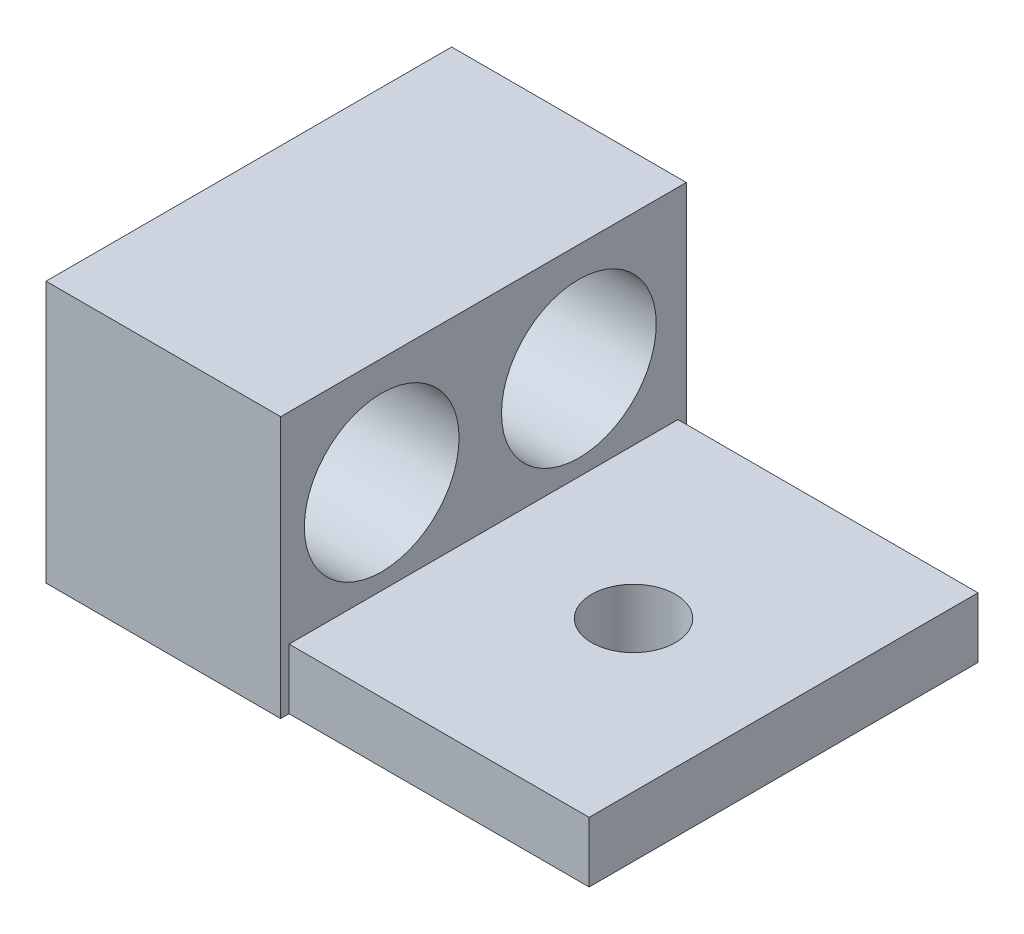
from build123d import *

# Parameters (mm, degrees)
SKETCH1_W           = 81.026
SKETCH1_H           = 39.624
BOSS_EXTRUDE1_DEPTH = 61.468
SKETCH5_W           = 45.466
SKETCH5_H           = 30.48
CUT_EXTRUDE1_DEPTH  = 62.468
SKETCH6_W           = 45.466
SKETCH6_H           = 1.27
CUT_EXTRUDE2_DEPTH  = 10.144
SKETCH7_R           = 6.35
CUT_EXTRUDE3_DEPTH  = 10.144
SKETCH8_R           = 11.7221
CUT_EXTRUDE4_DEPTH  = 36.56


with BuildPart() as part:
    # Sketch1 → Boss-Extrude1 (new body)
    with BuildSketch(Plane.XY):
        with Locations((40.513, 19.812)):
            Rectangle(SKETCH1_W, SKETCH1_H)
    extrude(amount=-BOSS_EXTRUDE1_DEPTH)

    # Sketch5 → Cut-Extrude1 (cut, through all)
    with BuildSketch(Plane.XY):
        with Locations((58.293, 24.384)):
            Rectangle(SKETCH5_W, SKETCH5_H)
    extrude(amount=-CUT_EXTRUDE1_DEPTH, mode=Mode.SUBTRACT)

    # Sketch6 → Cut-Extrude2 (cut, through all)
    with BuildSketch(Plane(origin=(0, 9.144, 0), x_dir=(1, 0, 0), z_dir=(0, 1, 0))):
        with Locations((58.293, 0.635)):
            Rectangle(SKETCH6_W, SKETCH6_H)
        with Locations((58.293, 60.833)):
            Rectangle(SKETCH6_W, SKETCH6_H)
    extrude(amount=-CUT_EXTRUDE2_DEPTH, mode=Mode.SUBTRACT)

    # Sketch7 → Cut-Extrude3 (cut, through all)
    with BuildSketch(Plane(origin=(0, 9.144, 0), x_dir=(1, 0, 0), z_dir=(0, 1, 0))):
        with Locations((58.293, 30.734)):
            Circle(SKETCH7_R)
    extrude(amount=-CUT_EXTRUDE3_DEPTH, mode=Mode.SUBTRACT)

    # Sketch8 → Cut-Extrude4 (cut, through all)
    with BuildSketch(Plane(origin=(35.56, 0, 0), x_dir=(0, 0, -1), z_dir=(1, 0, 0))):
        with Locations((15.307348572, 23.33723476)):
            Circle(SKETCH8_R)
        with Locations((45.18450858, 23.33723476)):
            Circle(SKETCH8_R)
    extrude(amount=-CUT_EXTRUDE4_DEPTH, mode=Mode.SUBTRACT)


solid = part.part
